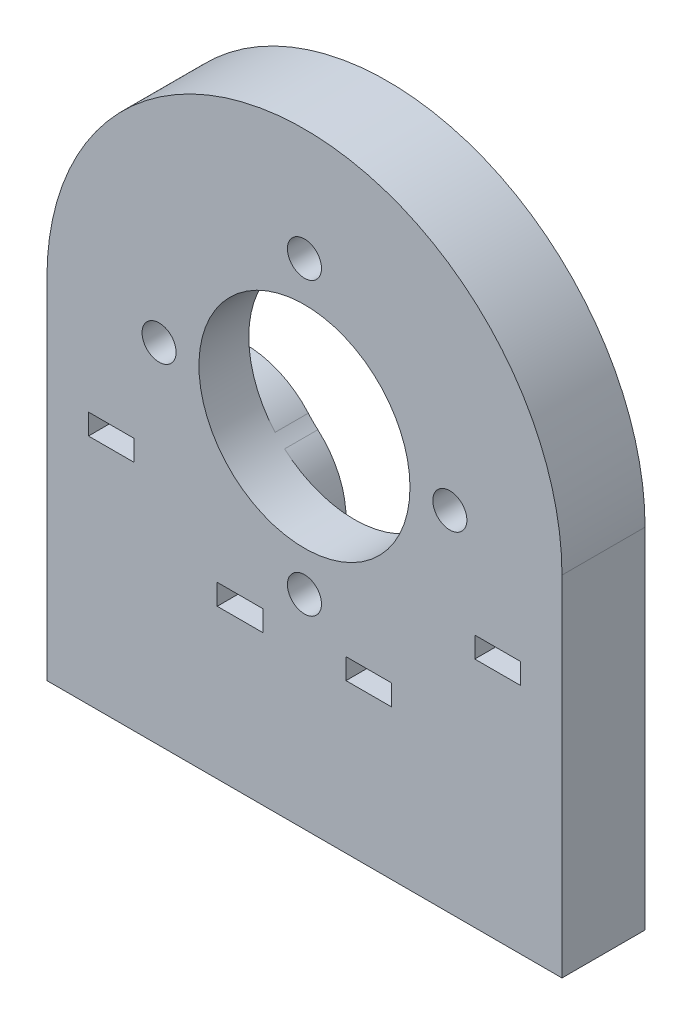
from build123d import *

# Parameters (mm, degrees)
SKETCH1_R                = 12.702118755
BOSS_EXTRUDE1_DEPTH      = 10
SKETCH1_3_R              = 5
CUT_EXTRUDE1_DEPTH       = 4
SKETCH1_4_R              = 2.05
CUT_EXTRUDE3_DEPTH       = 80.937475567
CUT_EXTRUDE3_DEPTH_BACK  = 80.937475567
FILLET1_R                = 10
CUT_EXTRUDE12_START      = -5
SKETCH3_W                = 5.5
SKETCH3_H                = 2.5
CUT_EXTRUDE12_DEPTH      = 80.937475709
CUT_EXTRUDE12_DEPTH_BACK = 2.75
CUT_EXTRUDE13_DEPTH      = 31.5
CUT_EXTRUDE14_DEPTH      = 21.5


with BuildPart() as part:
    # Sketch1 → Boss-Extrude1 (new body)
    with BuildSketch(Plane(origin=(0, 0, 0), x_dir=(0, 1, 0), z_dir=(0, 0, 1))):
        with BuildLine():
            Line((0, 31), (0, -31))
            Line((0, -31), (42, -31))
            ThreePointArc((42, -31), (73, 0), (42, 31))
            Line((42, 31), (0, 31))
        make_face()
        with Locations(Location((42, 0, 0), (0, 0, 270))):
            Circle(SKETCH1_R, mode=Mode.SUBTRACT)
    extrude(amount=BOSS_EXTRUDE1_DEPTH)

    # Sketch1_3 → Cut-Extrude1 (cut)
    with BuildSketch(Plane(origin=(0, 0, 0), x_dir=(0, 1, 0), z_dir=(0, 0, 1))):
        with Locations((59.5, 0)):
            Circle(SKETCH1_3_R)
        with Locations((42, -17.5)):
            Circle(SKETCH1_3_R)
        with Locations((24.5, 0)):
            Circle(SKETCH1_3_R)
        with Locations((42, 17.5)):
            Circle(SKETCH1_3_R)
    extrude(amount=CUT_EXTRUDE1_DEPTH, mode=Mode.SUBTRACT)

    # Sketch1_4 → Cut-Extrude3 (cut, two sides)
    with BuildSketch(Plane(origin=(0, 0, 0), x_dir=(0, 1, 0), z_dir=(0, 0, 1))) as cut_extrude3_sk:
        with Locations(Location((59.5, 0, 0), (0, 0, 270))):
            Circle(SKETCH1_4_R)
        with Locations(Location((42, -17.5, 0), (0, 0, 270))):
            Circle(SKETCH1_4_R)
        with Locations(Location((24.5, 0, 0), (0, 0, 270))):
            Circle(SKETCH1_4_R)
        with Locations(Location((42, 17.5, 0), (0, 0, 270))):
            Circle(SKETCH1_4_R)
    extrude(amount=CUT_EXTRUDE3_DEPTH, mode=Mode.SUBTRACT)
    extrude(cut_extrude3_sk.sketch, amount=-CUT_EXTRUDE3_DEPTH_BACK, mode=Mode.SUBTRACT)

    # Fillet1
    fillet1_edges = [part.edges().sort_by_distance(p)[0] for p in [
        (-1.197579289, 29.354462261, 2),
        (1.197579289, 29.354462261, 2),
        (-12.645537739, 43.197579289, 2),
        (-12.645537739, 40.802420711, 2),
        (1.197579289, 54.645537739, 2),
        (-1.197579289, 54.645537739, 2),
        (12.645537739, 40.802420711, 2),
        (12.645537739, 43.197579289, 2),
    ]]
    fillet(fillet1_edges, radius=FILLET1_R)

    # Sketch3 → Cut-Extrude12 (cut, two sides)
    with BuildSketch(Plane.XY.offset(10).offset(CUT_EXTRUDE12_START)) as cut_extrude12_sk:
        with Locations((-23.25, 29.25)):
            Rectangle(SKETCH3_W, SKETCH3_H)
        with Locations((-7.75, 19.25)):
            Rectangle(SKETCH3_W, SKETCH3_H)
        with Locations((7.75, 19.25)):
            Rectangle(SKETCH3_W, SKETCH3_H)
        with Locations((23.25, 29.25)):
            Rectangle(SKETCH3_W, SKETCH3_H)
    extrude(amount=CUT_EXTRUDE12_DEPTH, mode=Mode.SUBTRACT)
    extrude(cut_extrude12_sk.sketch, amount=-CUT_EXTRUDE12_DEPTH_BACK, mode=Mode.SUBTRACT)

    # Sketch2 → Cut-Extrude13 (cut)
    with BuildSketch(Plane.XZ):
        with BuildLine():
            Line((-22.332277702, 3.689356729), (-23.25, 3.046760658))
            Line((-23.25, 3.046760658), (-24.167722298, 3.689356729))
            ThreePointArc((-24.167722298, 3.689356729), (-23.25, 6.6), (-22.332277702, 3.689356729))
        make_face()
        with BuildLine():
            Line((22.332277702, 3.689356729), (23.25, 3.046760658))
            Line((23.25, 3.046760658), (24.167722298, 3.689356729))
            ThreePointArc((24.167722298, 3.689356729), (23.25, 6.6), (22.332277702, 3.689356729))
        make_face()
    extrude(amount=-CUT_EXTRUDE13_DEPTH, mode=Mode.SUBTRACT)

    # Sketch2_3 → Cut-Extrude14 (cut)
    with BuildSketch(Plane.XZ):
        with BuildLine():
            Line((-8.667722298, 3.689356729), (-7.75, 3.046760658))
            Line((-7.75, 3.046760658), (-6.832277702, 3.689356729))
            ThreePointArc((-6.832277702, 3.689356729), (-7.75, 6.6), (-8.667722298, 3.689356729))
        make_face()
        with BuildLine():
            Line((6.832277702, 3.689356729), (7.75, 3.046760658))
            Line((7.75, 3.046760658), (8.667722298, 3.689356729))
            ThreePointArc((8.667722298, 3.689356729), (7.75, 6.6), (6.832277702, 3.689356729))
        make_face()
    extrude(amount=-CUT_EXTRUDE14_DEPTH, mode=Mode.SUBTRACT)


solid = part.part
